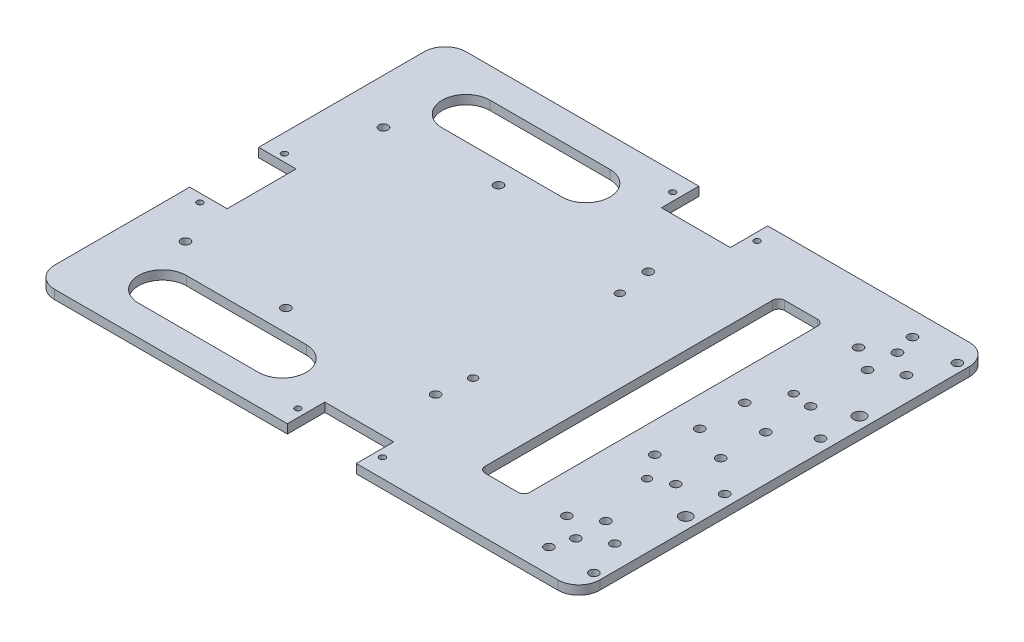
from build123d import *

# Parameters (mm, degrees)
SKETCH1_W           = 182
SKETCH1_H           = 137.36
BOSS_EXTRUDE1_DEPTH = 3
SKETCH2_R           = 1.5
CUT_EXTRUDE1_DEPTH  = 4
SKETCH3_R           = 1
CUT_EXTRUDE2_DEPTH  = 4
SKETCH4_W           = 23
SKETCH4_H           = 12.5
CUT_EXTRUDE3_DEPTH  = 4
SKETCH5_R           = 1.35
CUT_EXTRUDE4_DEPTH  = 4
SKETCH6_R           = 1.5
CUT_EXTRUDE5_DEPTH  = 4
CUT_EXTRUDE6_DEPTH  = 4
FILLET1_R           = 7
SKETCH10_R          = 1.5
CUT_EXTRUDE9_DEPTH  = 4
SKETCH11_R          = 1.5
CUT_EXTRUDE10_DEPTH = 4
CUT_EXTRUDE11_REACH = 5
SKETCH13_W          = 12.5
SKETCH13_H          = 23
SKETCH14_R          = 1
CUT_EXTRUDE12_DEPTH = 4
SKETCH15_R          = 2
CUT_EXTRUDE13_DEPTH = 4
SKETCH16_R          = 1.5
CUT_EXTRUDE14_DEPTH = 4


with BuildPart() as part:
    # Sketch1 → Boss-Extrude1 (new body)
    with BuildSketch(Plane(origin=(0, 0, 0), x_dir=(1, 0, 0), z_dir=(0, 1, 0))):
        with Locations((8.068181818, 1013.883570356)):
            Rectangle(SKETCH1_W, SKETCH1_H)
    extrude(amount=BOSS_EXTRUDE1_DEPTH)

    # Sketch2 → Cut-Extrude1 (cut, through all)
    with BuildSketch(Plane.XZ):
        with Locations((95.068181818, -1029.883570356)):
            Circle(SKETCH2_R)
        with Locations((95.068181818, -997.883570356)):
            Circle(SKETCH2_R)
    extrude(amount=-CUT_EXTRUDE1_DEPTH, mode=Mode.SUBTRACT)

    # Sketch3 → Cut-Extrude2 (cut, through all)
    with BuildSketch(Plane(origin=(0, 3, 0), x_dir=(1, 0, 0), z_dir=(0, 1, 0))):
        with Locations((27.328181818, 1076.423570356)):
            Circle(SKETCH3_R)
        with Locations((-0.871818182, 1076.423570356)):
            Circle(SKETCH3_R)
        with Locations((-0.871818182, 951.363570356)):
            Circle(SKETCH3_R)
        with Locations((27.328181818, 951.363570356)):
            Circle(SKETCH3_R)
    extrude(amount=-CUT_EXTRUDE2_DEPTH, mode=Mode.SUBTRACT)

    # Sketch4 → Cut-Extrude3 (cut, through all)
    with BuildSketch(Plane(origin=(0, 3, 0), x_dir=(1, 0, 0), z_dir=(0, 1, 0))):
        with Locations((13.268181818, 951.453570356)):
            Rectangle(SKETCH4_W, SKETCH4_H)
        with Locations((13.268181818, 1076.313570356)):
            Rectangle(SKETCH4_W, SKETCH4_H)
    extrude(amount=-CUT_EXTRUDE3_DEPTH, mode=Mode.SUBTRACT)

    # Sketch5 → Cut-Extrude4 (cut, through all)
    with BuildSketch(Plane.XZ):
        with Locations((77.568181818, -1038.383570356)):
            Circle(SKETCH5_R)
        with Locations((77.668181818, -989.343570356)):
            Circle(SKETCH5_R)
        with Locations((19.568181818, -1038.383570356)):
            Circle(SKETCH5_R)
        with Locations((19.568181818, -989.383570356)):
            Circle(SKETCH5_R)
    extrude(amount=-CUT_EXTRUDE4_DEPTH, mode=Mode.SUBTRACT)

    # Sketch6 → Cut-Extrude5 (cut, through all)
    with BuildSketch(Plane(origin=(0, 3, 0), x_dir=(1, 0, 0), z_dir=(0, 1, 0))):
        with Locations((18.062803793, 1049.383570356)):
            Circle(SKETCH6_R)
        with Locations((-31.937196207, 1049.383570356)):
            Circle(SKETCH6_R)
        with Locations((-31.937196207, 978.387370356)):
            Circle(SKETCH6_R)
        with Locations((18.062803793, 978.387370356)):
            Circle(SKETCH6_R)
    extrude(amount=-CUT_EXTRUDE5_DEPTH, mode=Mode.SUBTRACT)

    # Sketch7 → Cut-Extrude6 (cut, through all)
    with BuildSketch(Plane(origin=(0, 3, 0), x_dir=(1, 0, 0), z_dir=(0, 1, 0))):
        with BuildLine():
            Line((49.068181818, 1063.883570356), (60.068181818, 1063.883570356))
            ThreePointArc((60.068181818, 1063.883570356), (61.482395381, 1063.297783918), (62.068181818, 1061.883570356))
            Line((62.068181818, 1061.883570356), (62.068181818, 965.883570356))
            ThreePointArc((62.068181818, 965.883570356), (61.482395381, 964.469356794), (60.068181818, 963.883570356))
            Line((60.068181818, 963.883570356), (49.068181818, 963.883570356))
            ThreePointArc((49.068181818, 963.883570356), (47.653968256, 964.469356794), (47.068181818, 965.883570356))
            Line((47.068181818, 965.883570356), (47.068181818, 1061.883570356))
            ThreePointArc((47.068181818, 1061.883570356), (47.653968256, 1063.297783918), (49.068181818, 1063.883570356))
        make_face()
        with BuildLine():
            Line((-17.931818182, 1056.563570356), (-57.931818182, 1056.563570356))
            ThreePointArc((-57.931818182, 1056.563570356), (-65.931818182, 1064.563570356), (-57.931818182, 1072.563570356))
            Line((-57.931818182, 1072.563570356), (-17.931818182, 1072.563570356))
            ThreePointArc((-17.931818182, 1072.563570356), (-9.931818182, 1064.563570356), (-17.931818182, 1056.563570356))
        make_face()
        with BuildLine():
            Line((-17.931818182, 955.203570356), (-57.931818182, 955.203570356))
            ThreePointArc((-57.931818182, 955.203570356), (-65.931818182, 963.203570356), (-57.931818182, 971.203570356))
            Line((-57.931818182, 971.203570356), (-17.931818182, 971.203570356))
            ThreePointArc((-17.931818182, 971.203570356), (-9.931818182, 963.203570356), (-17.931818182, 955.203570356))
        make_face()
    extrude(amount=-CUT_EXTRUDE6_DEPTH, mode=Mode.SUBTRACT)

    # Fillet1
    fillet1_edges = [part.edges().sort_by_distance(p)[0] for p in [
        (-82.931818182, 1.5, -1082.563570356),
        (99.068181818, 1.5, -1082.563570356),
        (99.068181818, 1.5, -945.203570356),
        (-82.931818182, 1.5, -945.203570356),
    ]]
    fillet(fillet1_edges, radius=FILLET1_R)

    # Sketch10 → Cut-Extrude9 (cut, through all)
    with BuildSketch(Plane(origin=(0, 3, 0), x_dir=(1, 0, 0), z_dir=(0, 1, 0))):
        with Locations((96.068181818, 1074.563570356)):
            Circle(SKETCH10_R)
        with Locations((81.068181818, 1074.563570356)):
            Circle(SKETCH10_R)
        with Locations((81.068181818, 953.203570356)):
            Circle(SKETCH10_R)
        with Locations((96.068181818, 953.203570356)):
            Circle(SKETCH10_R)
    extrude(amount=-CUT_EXTRUDE9_DEPTH, mode=Mode.SUBTRACT)

    # Sketch11 → Cut-Extrude10 (cut, through all)
    with BuildSketch(Plane.XZ):
        with Locations((-67.845029609, -1046.883570356)):
            Circle(SKETCH11_R)
        with Locations((-67.931818182, -980.883570356)):
            Circle(SKETCH11_R)
    extrude(amount=-CUT_EXTRUDE10_DEPTH, mode=Mode.SUBTRACT)

    # Sketch13 → Cut-Extrude11 (cut, up to next)
    with BuildSketch(Plane.XZ, mode=Mode.PRIVATE) as cut_extrude11_sk1:
        with Locations((-76.681818182, -1008.803570356)):
            Rectangle(SKETCH13_W, SKETCH13_H)
    cut_extrude11_tool1 = extrude(cut_extrude11_sk1.sketch, amount=-CUT_EXTRUDE11_REACH, mode=Mode.PRIVATE) & part.part
    add(cut_extrude11_tool1.solids().sort_by_distance((-76.681818, 0, -1008.80357))[0], mode=Mode.SUBTRACT)

    # Sketch14 → Cut-Extrude12 (cut, through all)
    with BuildSketch(Plane(origin=(0, 3, 0), x_dir=(1, 0, 0), z_dir=(0, 1, 0))):
        with Locations((-76.787040817, 994.553570356)):
            Circle(SKETCH14_R)
        with Locations((-76.787040817, 1022.753570356)):
            Circle(SKETCH14_R)
    extrude(amount=-CUT_EXTRUDE12_DEPTH, mode=Mode.SUBTRACT)

    # Sketch15 → Cut-Extrude13 (cut, through all)
    with BuildSketch(Plane.XZ):
        with Locations((95.068181818, -1042.883570356)):
            Circle(SKETCH15_R)
        with Locations((95.068181818, -984.883570356)):
            Circle(SKETCH15_R)
    extrude(amount=-CUT_EXTRUDE13_DEPTH, mode=Mode.SUBTRACT)

    # Sketch16 → Cut-Extrude14 (cut, through all)
    with BuildSketch(Plane(origin=(0, 3, 0), x_dir=(1, 0, 0), z_dir=(0, 1, 0))):
        with Locations((72.068181818, 1027.563570356)):
            Circle(SKETCH16_R)
        with Locations((72.068181818, 1012.563570356)):
            Circle(SKETCH16_R)
        with Locations((72.068181818, 997.563570356)):
            Circle(SKETCH16_R)
        with Locations((84.068181818, 1007.563570356)):
            Circle(SKETCH16_R)
        with Locations((84.068181818, 1022.563570356)):
            Circle(SKETCH16_R)
        with Locations((84.068181818, 1037.563570356)):
            Circle(SKETCH16_R)
        with Locations((75.068181818, 1062.563570356)):
            Circle(SKETCH16_R)
        with Locations((91.068181818, 1062.563570356)):
            Circle(SKETCH16_R)
        with Locations((83.068181818, 1057.563570356)):
            Circle(SKETCH16_R)
        with Locations((83.068181818, 1067.563570356)):
            Circle(SKETCH16_R)
        with Locations((91.068181818, 965.203570356)):
            Circle(SKETCH16_R)
        with Locations((75.068181818, 965.203570356)):
            Circle(SKETCH16_R)
        with Locations((83.068181818, 970.203570356)):
            Circle(SKETCH16_R)
        with Locations((83.068181818, 960.203570356)):
            Circle(SKETCH16_R)
        with Locations((84.068181818, 992.563570356)):
            Circle(SKETCH16_R)
    extrude(amount=-CUT_EXTRUDE14_DEPTH, mode=Mode.SUBTRACT)


solid = part.part
